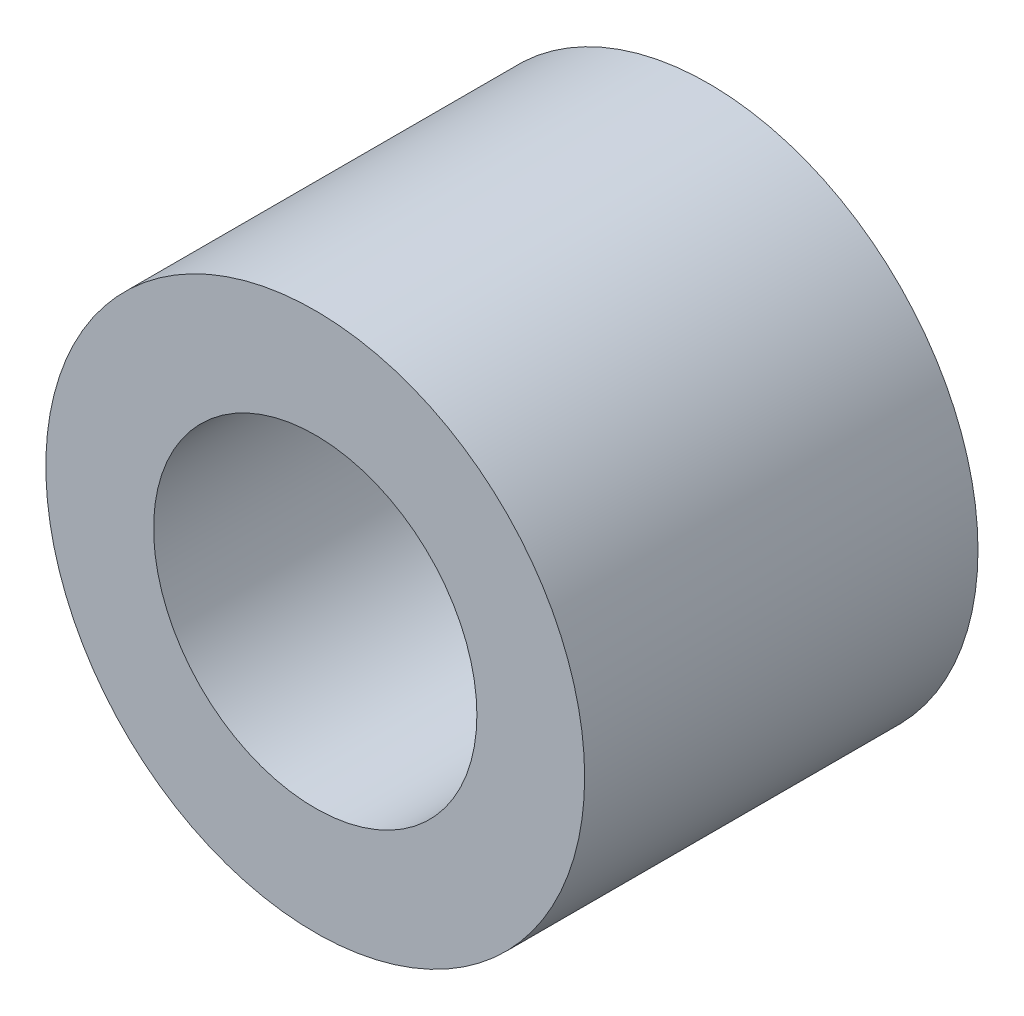
from build123d import *

# Parameters (mm, degrees)
SKETCH2_R           = 2.5
SKETCH2_R_2         = 1.5
BOSS_EXTRUDE1_DEPTH = 3.65


with BuildPart() as part:
    # Sketch2 → Boss-Extrude1 (new body)
    with BuildSketch(Plane.XY):
        Circle(SKETCH2_R)
        Circle(SKETCH2_R_2, mode=Mode.SUBTRACT)
    extrude(amount=BOSS_EXTRUDE1_DEPTH)


solid = part.part
